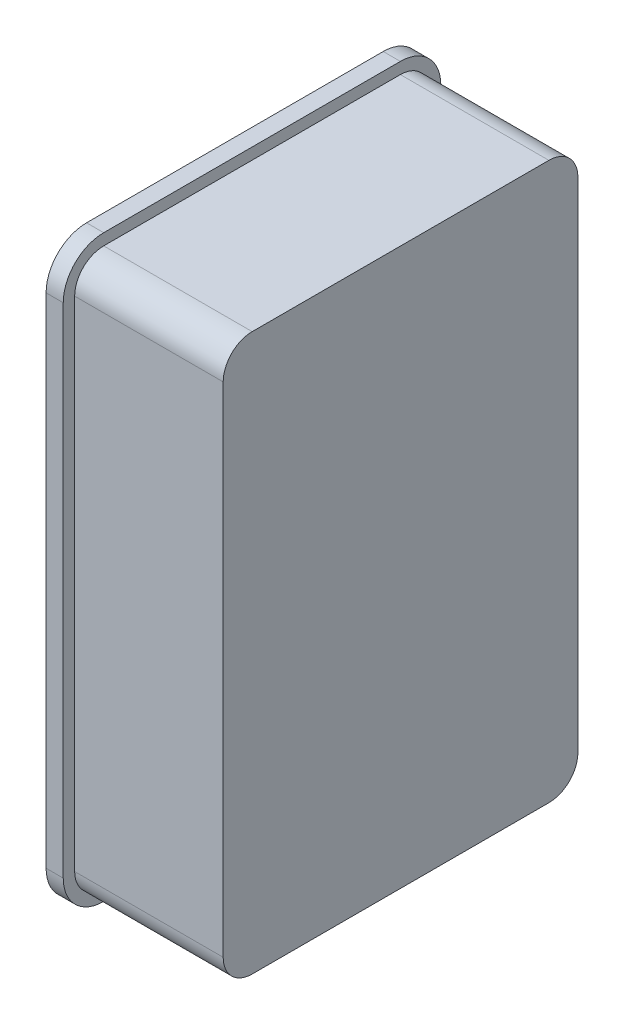
from build123d import *

# Parameters (mm, degrees)
SKETCH2_W                        = 36
SKETCH2_H                        = 12
BOSS_EXTRUDE2_DEPTH              = 12
BOSS_EXTRUDE3_DEPTH              = 1
BOSS_EXTRUDE5_DEPTH              = 1.5
BOSS_EXTRUDE10_REACH             = 44.882
BOSS_EXTRUDE10_DIRECTION_2_REACH = 44.882
SKETCH15_OUTSIDE_W               = 65.146
SKETCH15_OUTSIDE_H               = 47.496
CUT_OFF_EXTRA_EDGES_DEPTH        = 47


with BuildPart() as part:
    # Sketch2 → Boss-Extrude2 (new body)
    with BuildSketch(Plane(origin=(0, 0, 0), x_dir=(0, -1, 0), z_dir=(1, 0, 0))):
        with BuildLine():
            Line((6.35, 2.54), (6.35, 28.51))
            ThreePointArc((6.35, 28.51), (5.606051224, 30.306051224), (3.81, 31.05))
            Line((3.81, 31.05), (-39.81, 31.05))
            ThreePointArc((-39.81, 31.05), (-41.606051224, 30.306051224), (-42.35, 28.51))
            Line((-42.35, 28.51), (-42.35, 2.54))
            ThreePointArc((-42.35, 2.54), (-41.606051224, 0.743948776), (-39.81, 0))
            Line((-39.81, 0), (3.81, 0))
            ThreePointArc((3.81, 0), (5.606051224, 0.743948776), (6.35, 2.54))
        make_face()
        with Locations((-18, 15.525)):
            Rectangle(SKETCH2_W, SKETCH2_H, mode=Mode.SUBTRACT)
    extrude(amount=BOSS_EXTRUDE2_DEPTH)

    # Sketch3 → Boss-Extrude3 (add)
    with BuildSketch(Plane.YZ.offset(12)):
        with BuildLine():
            Line((-6.35, -2.54), (-6.35, -28.51))
            ThreePointArc((-6.35, -28.51), (-5.606051224, -30.306051224), (-3.81, -31.05))
            Line((-3.81, -31.05), (39.81, -31.05))
            ThreePointArc((39.81, -31.05), (41.606051224, -30.306051224), (42.35, -28.51))
            Line((42.35, -28.51), (42.35, -2.54))
            ThreePointArc((42.35, -2.54), (41.606051224, -0.743948776), (39.81, 0))
            Line((39.81, 0), (-3.81, 0))
            ThreePointArc((-3.81, 0), (-5.606051224, -0.743948776), (-6.35, -2.54))
        make_face()
    extrude(amount=BOSS_EXTRUDE3_DEPTH)


with BuildPart() as body_2:
    # Sketch6 → Boss-Extrude5 (new body)
    with BuildSketch(Plane(origin=(0, 0, 0), x_dir=(0, -1, 0), z_dir=(-1, 0, 0))):
        with BuildLine():
            Line((7.35, -2.54), (7.35, -28.51))
            ThreePointArc((7.35, -28.51), (6.313158005, -31.013158005), (3.81, -32.05))
            Line((3.81, -32.05), (-39.81, -32.05))
            ThreePointArc((-39.81, -32.05), (-42.313158005, -31.013158005), (-43.35, -28.51))
            Line((-43.35, -28.51), (-43.35, -2.54))
            ThreePointArc((-43.35, -2.54), (-42.313158005, -0.036841995), (-39.81, 1))
            Line((-39.81, 1), (3.81, 1))
            ThreePointArc((3.81, 1), (6.313158005, -0.036841995), (7.35, -2.54))
        make_face()
        with BuildLine():
            Line((6.35, -2.54), (6.35, -28.51))
            ThreePointArc((6.35, -28.51), (5.606051224, -30.306051224), (3.81, -31.05))
            Line((3.81, -31.05), (-39.81, -31.05))
            ThreePointArc((-39.81, -31.05), (-41.606051224, -30.306051224), (-42.35, -28.51))
            Line((-42.35, -28.51), (-42.35, -2.54))
            ThreePointArc((-42.35, -2.54), (-41.606051224, -0.743948776), (-39.81, 0))
            Line((-39.81, 0), (3.81, 0))
            ThreePointArc((3.81, 0), (5.606051224, -0.743948776), (6.35, -2.54))
        make_face(mode=Mode.SUBTRACT)
    extrude(amount=BOSS_EXTRUDE5_DEPTH)

    # Boss-Extrude10: up to this face of the body (flat: up to its plane)
    boss_extrude10_end = Plane(body_2.part.faces().sort_by_distance((-0.75, 42.35, -15.525))[0])
    # Sketch10 → Boss-Extrude10 (add, up to the picked face)
    with BuildSketch(Plane(origin=(0, 18, 0), x_dir=(1, 0, 0), z_dir=(0, 1, 0)), mode=Mode.PRIVATE) as boss_extrude10_sk1:
        Polygon((-1.1, 0), (-1.1, 2), (-1.5, 1.6), (-1.5, 0), align=None)
    boss_extrude10_tool1 = split(extrude(boss_extrude10_sk1.sketch, amount=BOSS_EXTRUDE10_REACH, mode=Mode.PRIVATE), bisect_by=boss_extrude10_end, keep=Keep.BOTH, mode=Mode.PRIVATE)
    # Sketch10 → Boss-Extrude10 (add, up to the picked face)
    with BuildSketch(Plane(origin=(0, 18, 0), x_dir=(1, 0, 0), z_dir=(0, 1, 0)), mode=Mode.PRIVATE) as boss_extrude10_sk2:
        Polygon((-1.5, 31.05), (-1.1, 31.05), (-1.1, 30.05), (-1.5, 30.45), align=None)
    boss_extrude10_tool2 = split(extrude(boss_extrude10_sk2.sketch, amount=BOSS_EXTRUDE10_REACH, mode=Mode.PRIVATE), bisect_by=boss_extrude10_end, keep=Keep.BOTH, mode=Mode.PRIVATE)
    add(boss_extrude10_tool1.solids().sort_by(Axis((-1.292593, 18, -0.903704), (0, 1, 0)))[0])
    add(boss_extrude10_tool2.solids().sort_by(Axis((-1.283333, 18, -30.641667), (0, 1, 0)))[0])

    # Boss-Extrude10 direction 2: up to this face of the body (flat: up to its plane)
    boss_extrude10_direction_2_end = Plane(body_2.part.faces().sort_by_distance((-0.75, -6.35, -15.525))[0])
    # Sketch10 → Boss-Extrude10 direction 2 (add, up to the picked face)
    with BuildSketch(Plane(origin=(0, 18, 0), x_dir=(1, 0, 0), z_dir=(0, 1, 0)), mode=Mode.PRIVATE) as boss_extrude10_direction_2_sk1:
        Polygon((-1.1, 0), (-1.1, 2), (-1.5, 1.6), (-1.5, 0), align=None)
    boss_extrude10_direction_2_tool1 = split(extrude(boss_extrude10_direction_2_sk1.sketch, amount=-BOSS_EXTRUDE10_DIRECTION_2_REACH, mode=Mode.PRIVATE), bisect_by=boss_extrude10_direction_2_end, keep=Keep.BOTH, mode=Mode.PRIVATE)
    # Sketch10 → Boss-Extrude10 direction 2 (add, up to the picked face)
    with BuildSketch(Plane(origin=(0, 18, 0), x_dir=(1, 0, 0), z_dir=(0, 1, 0)), mode=Mode.PRIVATE) as boss_extrude10_direction_2_sk2:
        Polygon((-1.5, 31.05), (-1.1, 31.05), (-1.1, 30.05), (-1.5, 30.45), align=None)
    boss_extrude10_direction_2_tool2 = split(extrude(boss_extrude10_direction_2_sk2.sketch, amount=-BOSS_EXTRUDE10_DIRECTION_2_REACH, mode=Mode.PRIVATE), bisect_by=boss_extrude10_direction_2_end, keep=Keep.BOTH, mode=Mode.PRIVATE)
    add(boss_extrude10_direction_2_tool1.solids().sort_by(Axis((-1.292593, 18, -0.903704), (0, -1, 0)))[0])
    add(boss_extrude10_direction_2_tool2.solids().sort_by(Axis((-1.283333, 18, -30.641667), (0, -1, 0)))[0])

    # Sketch15 outside → cut off extra edges (cut)
    with BuildSketch(Plane(origin=(-1.5, 0, 0), x_dir=(0, -1, 0), z_dir=(-1, 0, 0))):
        with Locations((-18, -15.525)):
            Rectangle(SKETCH15_OUTSIDE_W, SKETCH15_OUTSIDE_H)
        with BuildLine():
            Line((7.35, -28.51), (7.35, -2.54))
            ThreePointArc((7.35, -2.54), (6.313158005, -0.036841995), (3.81, 1))
            Line((3.81, 1), (-39.81, 1))
            ThreePointArc((-39.81, 1), (-42.313158005, -0.036841995), (-43.35, -2.54))
            Line((-43.35, -2.54), (-43.35, -28.51))
            ThreePointArc((-43.35, -28.51), (-42.313158005, -31.013158005), (-39.81, -32.05))
            Line((-39.81, -32.05), (3.81, -32.05))
            ThreePointArc((3.81, -32.05), (6.313158005, -31.013158005), (7.35, -28.51))
        make_face(mode=Mode.SUBTRACT)
    extrude(amount=-CUT_OFF_EXTRA_EDGES_DEPTH, mode=Mode.SUBTRACT)


solid = Compound([part.part, body_2.part])
